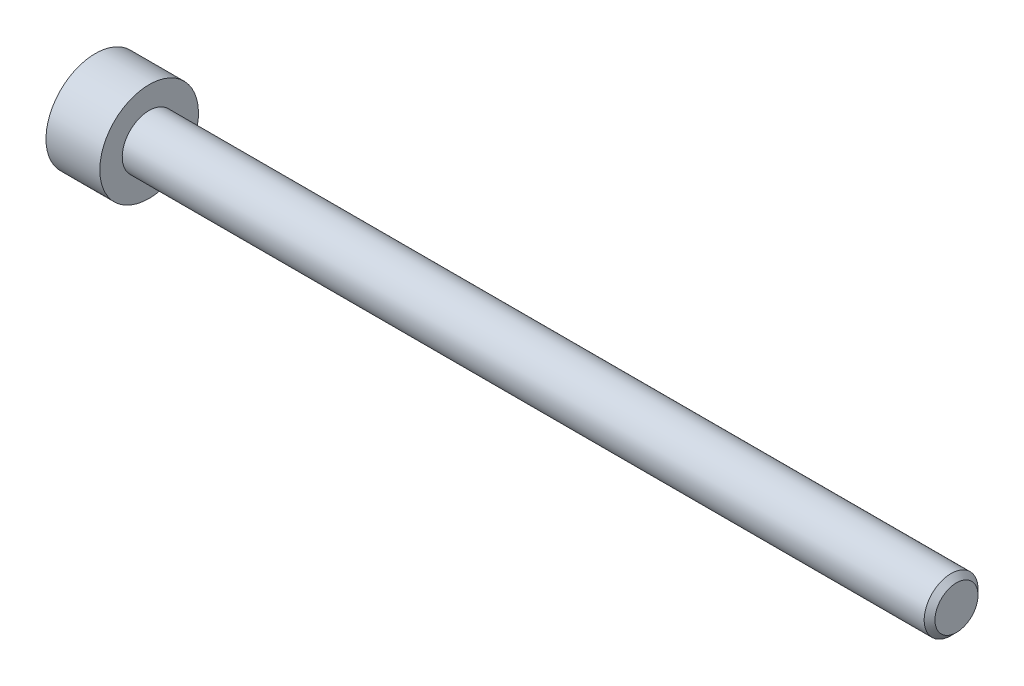
from build123d import *

# Parameters (mm, degrees)
SKETCH2_R           = 1.5
BOSS_EXTRUDE1_DEPTH = 45
CHAMFER1_SIZE       = 0.3
SKETCH6_W           = 3
SKETCH6_H           = 2.75
CUT_EXTRUDE1_DEPTH  = 1.6
SKETCH8_R           = 1.493375673
CUT_EXTRUDE2_DEPTH  = 1
CUT_EXTRUDE2_TAPER  = 45


with BuildPart() as part:
    # Sketch2 → Boss-Extrude1 (new body)
    with BuildSketch(Plane(origin=(0, 0, 0), x_dir=(0, 0, -1), z_dir=(1, 0, 0))):
        Circle(SKETCH2_R)
    extrude(amount=-BOSS_EXTRUDE1_DEPTH)

    # Chamfer1
    chamfer1_edges = [part.edges().sort_by_distance(p)[0] for p in [
        (0, 0, 1.5),
    ]]
    chamfer(chamfer1_edges, length=CHAMFER1_SIZE)

    # Sketch6 → Revolve1 (revolve)
    with BuildSketch(Plane.XY):
        with Locations((-46.5, 1.375)):
            Rectangle(SKETCH6_W, SKETCH6_H)
    revolve(axis=Axis((-45, 0, 0), (1, 0, 0)))

    # Sketch7 → Cut-Extrude1 (cut)
    with BuildSketch(Plane.ZY.offset(48)):
        Polygon((0, 1.443375673), (-1.25, 0.721687836), (-1.25, -0.721687836), (0, -1.443375673), (1.25, -0.721687836), (1.25, 0.721687836), align=None)
    extrude(amount=-CUT_EXTRUDE1_DEPTH, mode=Mode.SUBTRACT)

    # Sketch8 → Cut-Extrude2 (cut)
    with BuildSketch(Plane.ZY.offset(48)):
        Circle(SKETCH8_R)
    extrude(amount=-CUT_EXTRUDE2_DEPTH, taper=CUT_EXTRUDE2_TAPER, mode=Mode.SUBTRACT)


solid = part.part
